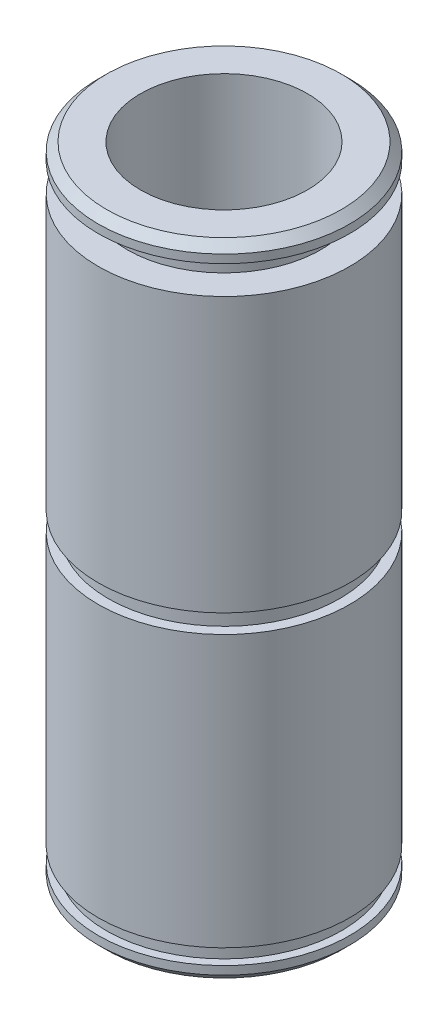
from build123d import *

# Parameters (mm, degrees)
CHAMFER1_SIZE = 0.635


with BuildPart() as part:
    # Sketch1 → Revolve1 (revolve)
    with BuildSketch(Plane.XY):
        Polygon((-9.5631, 24.49576), (-9.5631, 45.33392), (-7.366, 45.33392), (-7.366, 47.49292), (-9.5631, 47.49292), (-9.5631, 48.76292), (-6.35, 48.76292), (-6.35, 0), (-9.5631, 0), (-9.5631, 1.27), (-8.9408, 1.27), (-8.9408, 2.4384), (-9.5631, 2.4384), (-9.5631, 23.07336), (-8.8011, 23.07336), (-8.8011, 24.49576), align=None)
    revolve(axis=Axis((0, 55, 0), (0, -1, 0)))

    # Chamfer1
    chamfer1_edges = [part.edges().sort_by_distance(p)[0] for p in [
        (9.5631, 0, 0),
        (9.5631, 48.76292, 0),
    ]]
    chamfer(chamfer1_edges, length=CHAMFER1_SIZE)


solid = part.part
